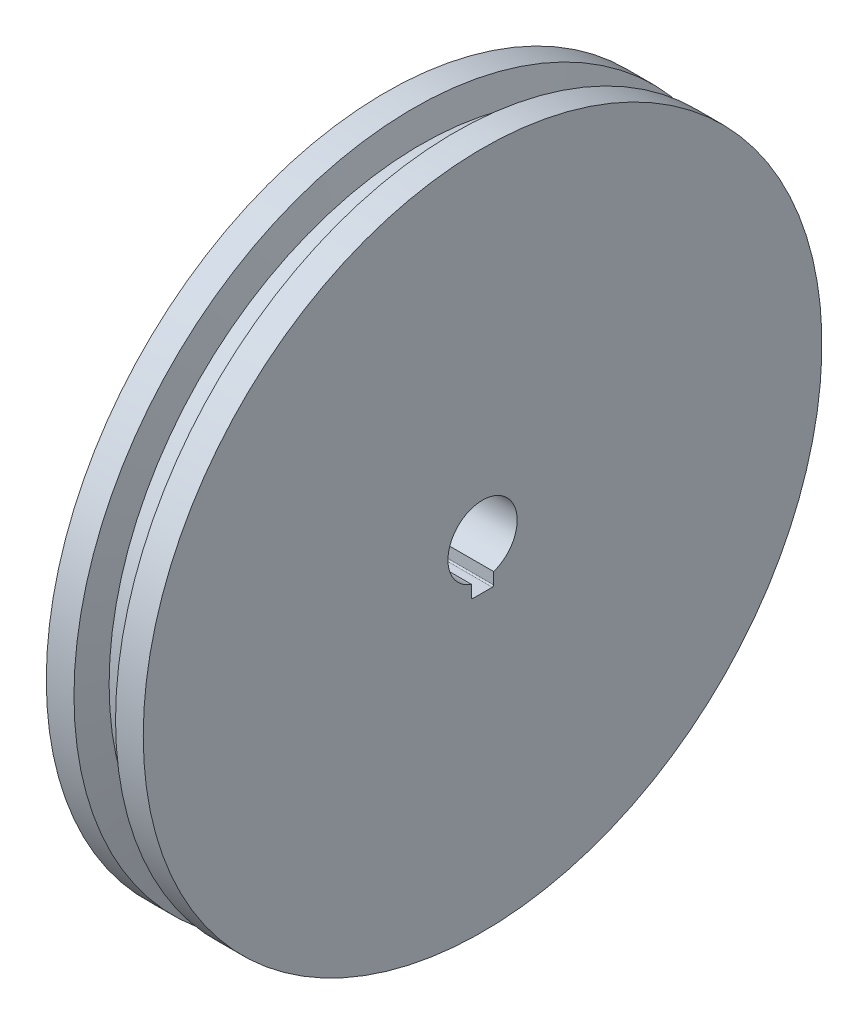
from build123d import *

# Parameters (mm, degrees)
CORTE_EXTRUS_O1_DEPTH = 71


with BuildPart() as part:
    # Sketch1 → Revolve1 (revolve)
    with BuildSketch(Plane.XY):
        Polygon((70, -12.5), (0, -12.5), (0, -30), (10, -30), (12.679491924, -20), (22.320508076, -20), (25, -30), (35, -30), (35, -122.5), (45, -122.5), (47.679491924, -112.5), (57.320508076, -112.5), (60, -122.5), (70, -122.5), align=None)
    revolve(axis=Axis((0, 0, 0), (1, 0, 0)))

    # Esboço1 → Corte-extrusão1 (cut, through all)
    with BuildSketch(Plane.ZY):
        with BuildLine():
            Line((3.5, -16.5), (-3.5, -16.5))
            ThreePointArc((-3.5, -16.5), (-3.853553391, -16.353553391), (-4, -16))
            Line((-4, -16), (-4, -8.5))
            Line((-4, -8.5), (4, -8.5))
            Line((4, -8.5), (4, -16))
            ThreePointArc((4, -16), (3.853553391, -16.353553391), (3.5, -16.5))
        make_face()
    extrude(amount=-CORTE_EXTRUS_O1_DEPTH, mode=Mode.SUBTRACT)


solid = part.part
